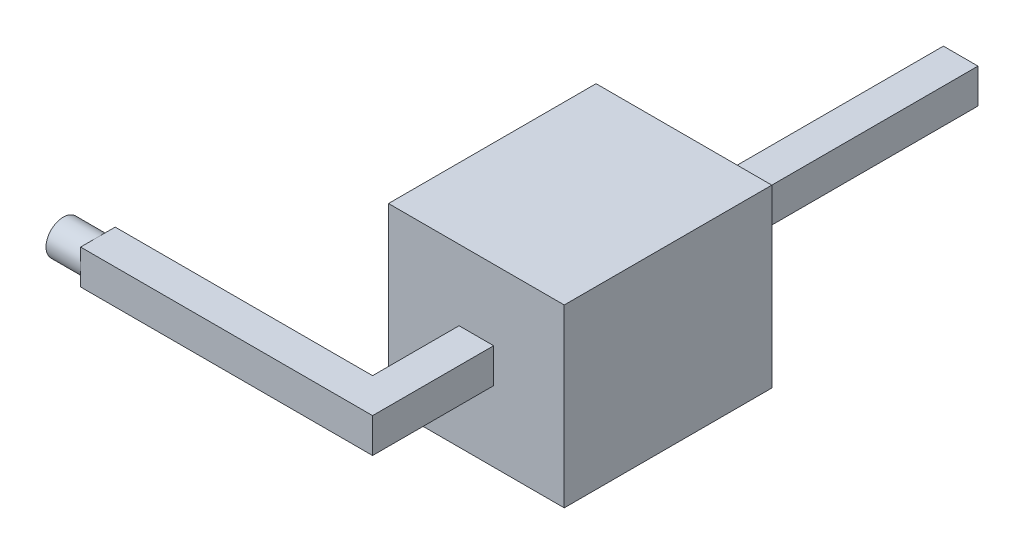
from build123d import *

# Parameters (mm, degrees)
BOSS_EXTRUDE1_DEPTH = 0.5
SKETCH2_W           = 2.54
SKETCH2_H           = 2.54
BOSS_EXTRUDE2_DEPTH = 3
SKETCH3_OUTSIDE_W   = 12.904
SKETCH3_OUTSIDE_H   = 6.694
SKETCH3_OUTSIDE_R   = 0.25
CUT_EXTRUDE1_DEPTH  = 0.5


with BuildPart() as part:
    # Sketch1 → Boss-Extrude1 (new body)
    with BuildSketch(Plane(origin=(0, 0, 0), x_dir=(1, 0, 0), z_dir=(0, 1, 0))):
        Polygon((0, 0), (4.72, 0), (4.72, 3.649976519), (4.72, 8.75), (4.22, 8.75), (4.22, 0.5), (0, 0.5), align=None)
    extrude(amount=BOSS_EXTRUDE1_DEPTH)

    # Sketch2 → Boss-Extrude2 (add)
    with BuildSketch(Plane(origin=(0, 0, -4.75), x_dir=(-1, 0, 0), z_dir=(0, 0, -1))):
        with Locations((-4.47, 0.25)):
            Rectangle(SKETCH2_W, SKETCH2_H)
    extrude(amount=-BOSS_EXTRUDE2_DEPTH)

    # Sketch3 outside → Cut-Extrude1 (cut)
    with BuildSketch(Plane.ZY):
        with Locations((-4.375, 0.25)):
            Rectangle(SKETCH3_OUTSIDE_W, SKETCH3_OUTSIDE_H)
        with Locations((-0.25, 0.25)):
            Circle(SKETCH3_OUTSIDE_R, mode=Mode.SUBTRACT)
    extrude(amount=-CUT_EXTRUDE1_DEPTH, mode=Mode.SUBTRACT)


solid = part.part
